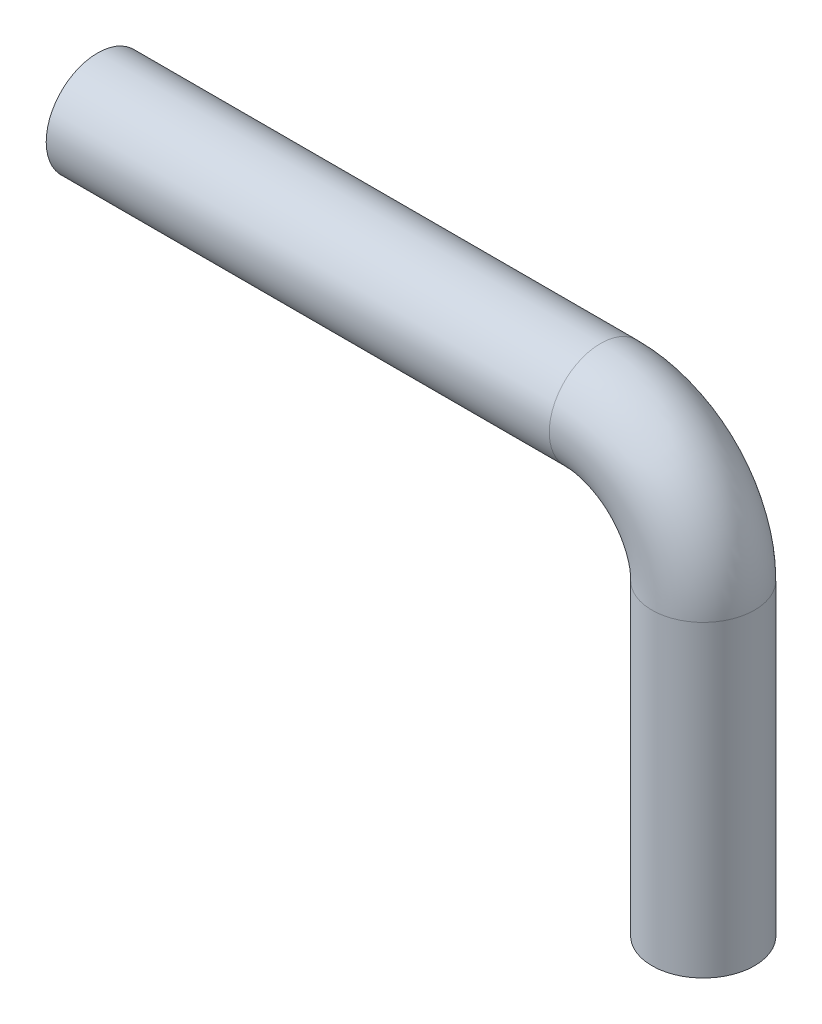
from build123d import *

# Parameters (mm, degrees)
SWEEP1_PROFILE_R = 5


with BuildPart() as part:
    # Sweep1: sweep along a path in Schizzo1
    with BuildLine(Plane.XY) as sweep1_path:
        Line((0, 0), (49, 0))
        ThreePointArc((49, 0), (56.071067812, -2.928932188), (59, -10))
        Line((59, -10), (59, -40))
    # Sweep1 profile (on start of the path) → Sweep1 (sweep)
    with BuildSketch(Plane(origin=(0, 0, 0), x_dir=(0, 0, 1), z_dir=(1, 0, 0))):
        Circle(SWEEP1_PROFILE_R)
    sweep(path=sweep1_path.line)


solid = part.part
